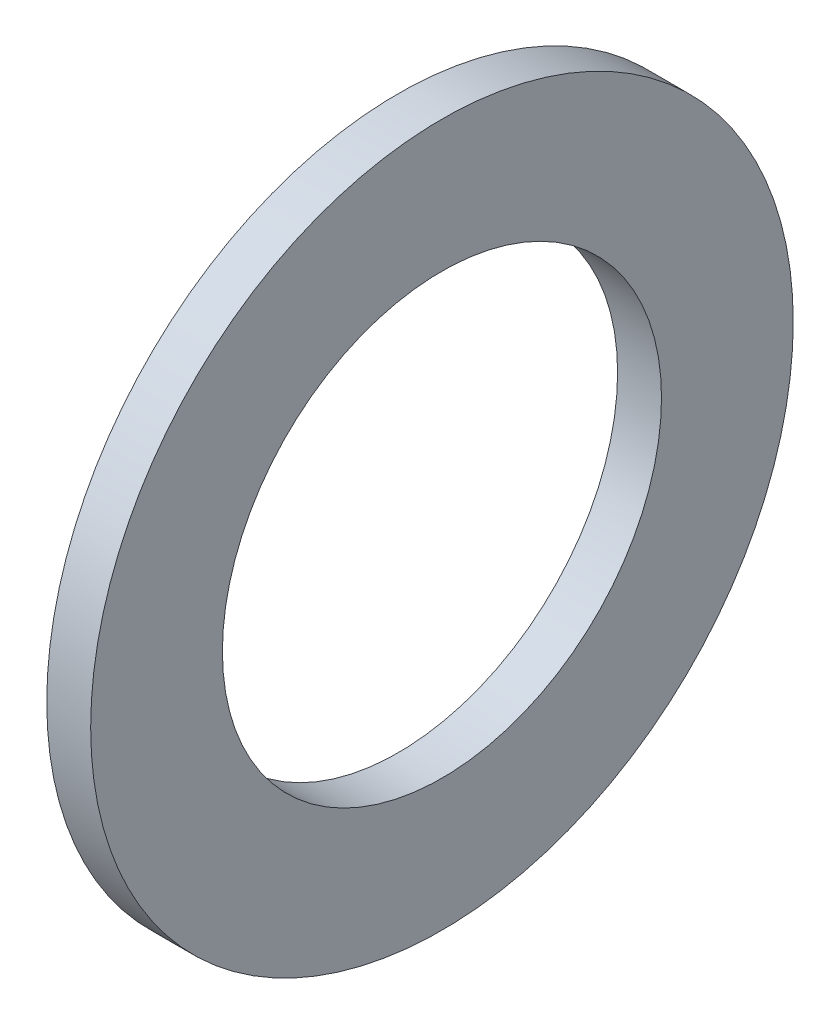
from build123d import *

# Parameters (mm, degrees)
SKETCH1_R           = 40
SKETCH1_R_2         = 25
BOSS_EXTRUDE1_DEPTH = 5


with BuildPart() as part:
    # Sketch1 → Boss-Extrude1 (new body)
    with BuildSketch(Plane(origin=(0, 0, 0), x_dir=(0, 0, -1), z_dir=(1, 0, 0))):
        Circle(SKETCH1_R)
        Circle(SKETCH1_R_2, mode=Mode.SUBTRACT)
    extrude(amount=BOSS_EXTRUDE1_DEPTH)


solid = part.part
